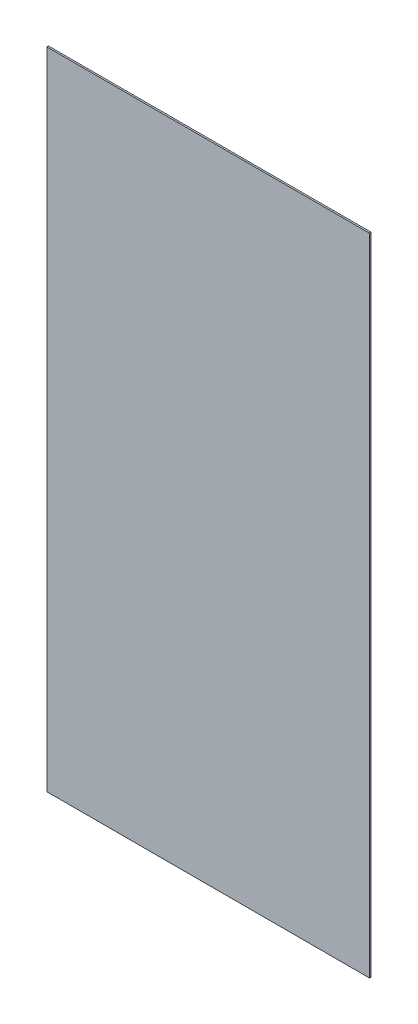
from build123d import *

# Parameters (mm, degrees)
SKETCH1_W           = 30
SKETCH1_H           = 60
BOSS_EXTRUDE1_DEPTH = 0.15


with BuildPart() as part:
    # Sketch1 → Boss-Extrude1 (new body)
    with BuildSketch(Plane.XY):
        Rectangle(SKETCH1_W, SKETCH1_H)
    extrude(amount=BOSS_EXTRUDE1_DEPTH)


solid = part.part
